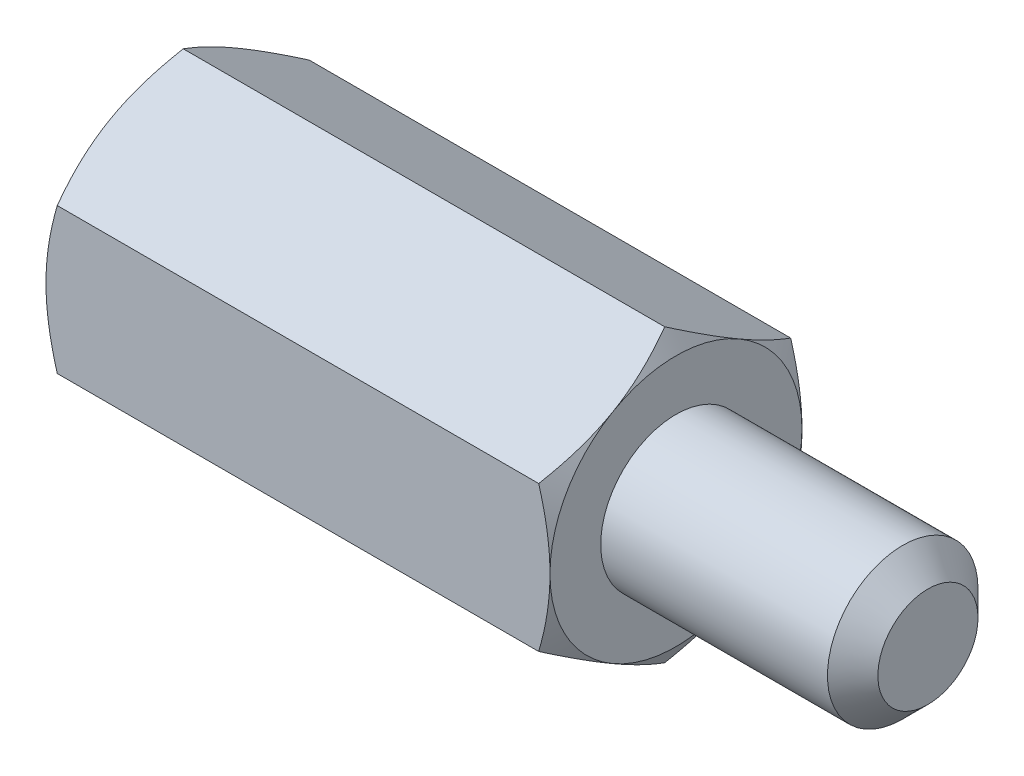
from build123d import *

# Parameters (mm, degrees)
SKETCH2_R         = 1.4224
EXTRUDE1_DEPTH    = 4.7625
CHAMFER1_SIZE     = 0.47625
EXTRUDE4_DEPTH    = 9.525
SKETCH8_OUTSIDE_W = 62.926
SKETCH8_OUTSIDE_H = 63.664
SKETCH8_OUTSIDE_R = 2.38125
EXTRUDE5_DEPTH    = 15.2875
EXTRUDE5_TAPER    = 60
SKETCH9_OUTSIDE_W = 46.428
SKETCH9_OUTSIDE_H = 47.166
SKETCH9_OUTSIDE_R = 2.38125
EXTRUDE6_DEPTH    = 10.525
EXTRUDE6_TAPER    = 60
SKETCH10_R        = 1.4224
EXTRUDE7_DEPTH    = 6.35


with BuildPart() as part:
    # Sketch2 → Extrude1 (new body)
    with BuildSketch(Plane(origin=(7.14375, 0, 0), x_dir=(0, 0, -1), z_dir=(1, 0, 0))):
        Circle(SKETCH2_R)
    extrude(amount=-EXTRUDE1_DEPTH)

    # Chamfer1
    chamfer1_edges = [part.edges().sort_by_distance(p)[0] for p in [
        (7.14375, 0, 1.4224),
    ]]
    chamfer(chamfer1_edges, length=CHAMFER1_SIZE)

    # Sketch7 → Extrude4 (add)
    with BuildSketch(Plane(origin=(2.38125, 0, 0), x_dir=(0, 0, -1), z_dir=(1, 0, 0))):
        Polygon((0, 2.749630657), (-2.38125, 1.374815329), (-2.38125, -1.374815329), (0, -2.749630657), (2.38125, -1.374815329), (2.38125, 1.374815329), align=None)
    extrude(amount=-EXTRUDE4_DEPTH)

    # Sketch8 outside → Extrude5 (cut, through all)
    with BuildSketch(Plane.ZY.offset(7.14375)):
        Rectangle(SKETCH8_OUTSIDE_W, SKETCH8_OUTSIDE_H)
        Circle(SKETCH8_OUTSIDE_R, mode=Mode.SUBTRACT)
    extrude(amount=-EXTRUDE5_DEPTH, taper=EXTRUDE5_TAPER, mode=Mode.SUBTRACT)

    # Sketch9 outside → Extrude6 (cut, through all)
    with BuildSketch(Plane(origin=(2.38125, 0, 0), x_dir=(0, 0, -1), z_dir=(1, 0, 0))):
        Rectangle(SKETCH9_OUTSIDE_W, SKETCH9_OUTSIDE_H)
        Circle(SKETCH9_OUTSIDE_R, mode=Mode.SUBTRACT)
    extrude(amount=-EXTRUDE6_DEPTH, taper=EXTRUDE6_TAPER, mode=Mode.SUBTRACT)

    # Sketch10 → Extrude7 (cut)
    with BuildSketch(Plane.ZY.offset(7.14375)):
        Circle(SKETCH10_R)
    extrude(amount=-EXTRUDE7_DEPTH, mode=Mode.SUBTRACT)


solid = part.part
